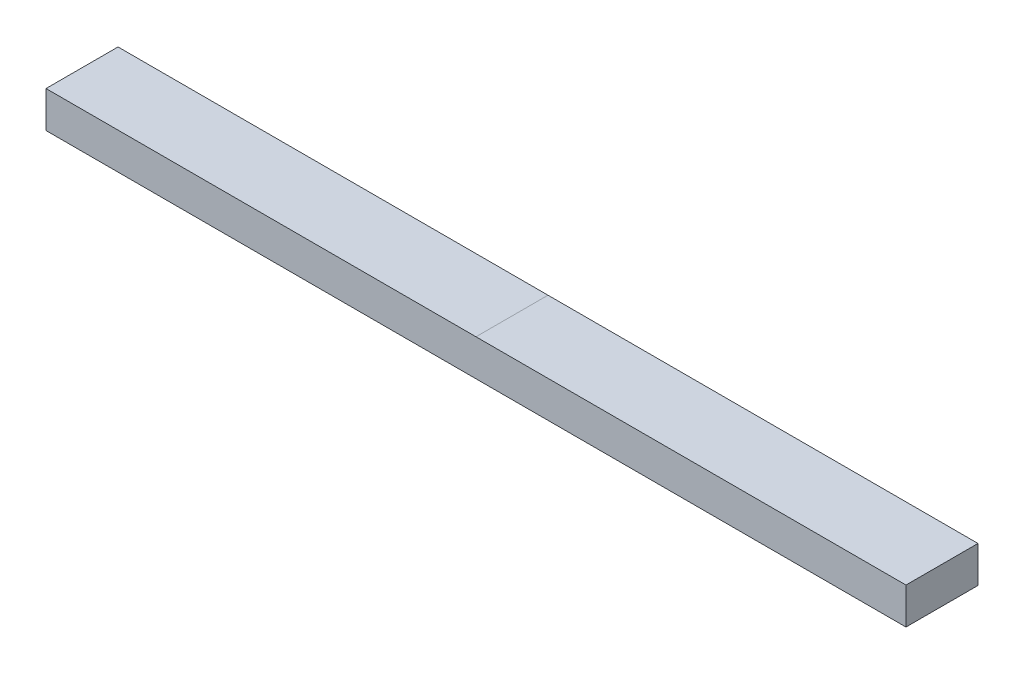
from build123d import *

# Parameters (mm, degrees)
SKETCH1_W           = 12.7635
SKETCH1_H           = 6.4516
BOSS_EXTRUDE1_DEPTH = 76.2


with BuildPart() as part:
    # Sketch1 → Boss-Extrude1 (new body, symmetric)
    with BuildSketch(Plane(origin=(0, 0, 0), x_dir=(0, 0, -1), z_dir=(1, 0, 0))):
        Rectangle(SKETCH1_W, SKETCH1_H)
    extrude(amount=BOSS_EXTRUDE1_DEPTH, both=True)


solid = part.part
